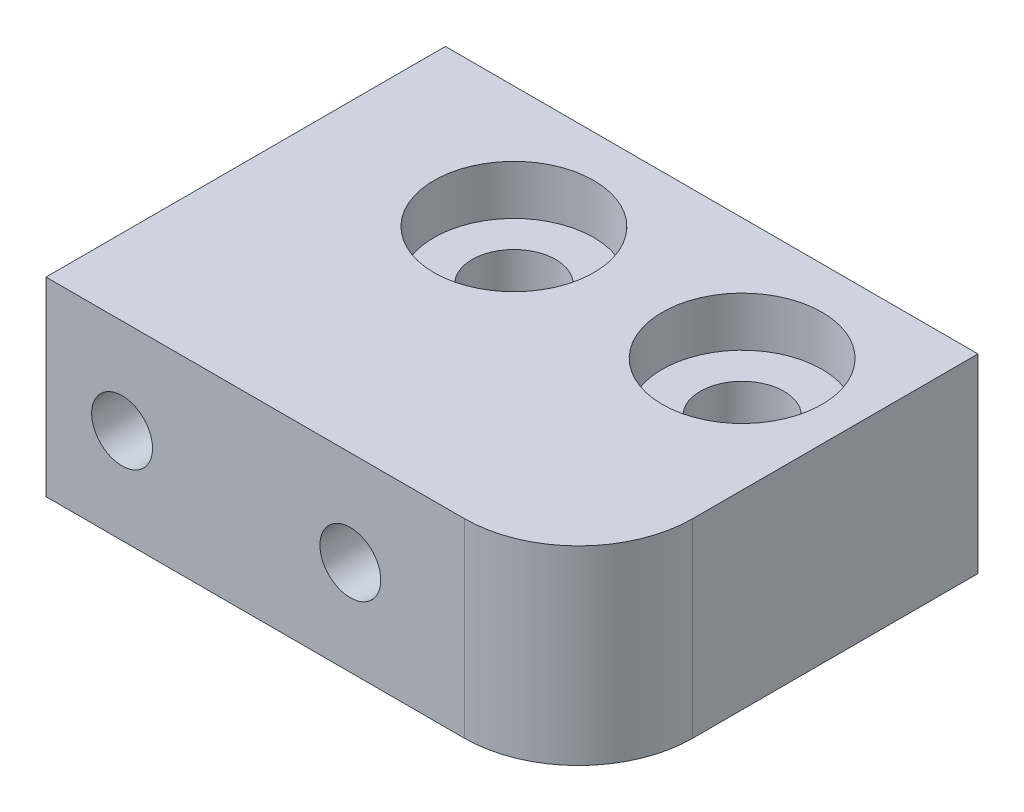
from build123d import *

# Parameters (mm, degrees)
SKETCH1_W           = 14
SKETCH1_H           = 10.5
BOSS_EXTRUDE1_DEPTH = 5
HOLE1_D             = 2.2
HOLE1_CBORE_D       = 4.2
HOLE1_CBORE_DEPTH   = 1.3
FILLET_2_R          = 3
M2X0_4_5_D          = 1.6


with BuildPart() as part:
    # Sketch1 → Boss-Extrude1 (new body)
    with BuildSketch(Plane(origin=(0, 0, 0), x_dir=(1, 0, 0), z_dir=(0, 1, 0))):
        Rectangle(SKETCH1_W, SKETCH1_H)
    extrude(amount=BOSS_EXTRUDE1_DEPTH)

    # Hole1 (through all)
    with Locations(Plane(origin=(0, 5, 0), x_dir=(1, 0, 0), z_dir=(0, 1, 0))):
        with Locations((-2, 2.05), (4, 2.05)):
            CounterBoreHole(HOLE1_D / 2, HOLE1_CBORE_D / 2, HOLE1_CBORE_DEPTH)

    # ﾌｨﾚｯﾄ2
    fillet_2_edges = [part.edges().sort_by_distance(p)[0] for p in [
        (7, 2.5, 5.25),
    ]]
    fillet(fillet_2_edges, radius=FILLET_2_R)

    # M2x0.4 ねじ穴5 (through all)
    with Locations(Plane(origin=(-5, 2.5, 5.25), x_dir=(1, 0, 0), z_dir=(0, 0, 1))):
        with Locations((0, 0), (6, 0)):
            Hole(M2X0_4_5_D / 2)


solid = part.part
